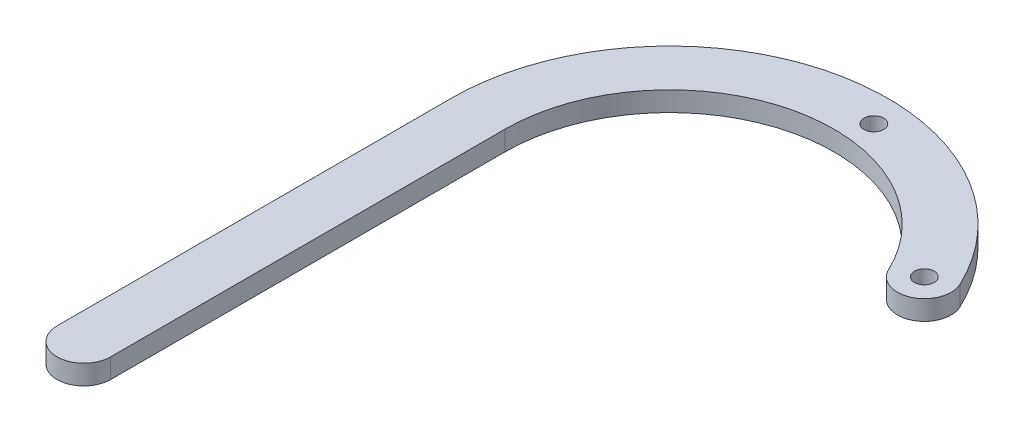
from build123d import *

# Parameters (mm, degrees)
BOSS_EXTRUDE1_DEPTH = 3.175
SKETCH5_R           = 1.5875
CUT_EXTRUDE1_DEPTH  = 4.175


with BuildPart() as part:
    # Sketch2 → Boss-Extrude1 (new body)
    with BuildSketch(Plane(origin=(0, 0, 0), x_dir=(1, 0, 0), z_dir=(0, 1, 0))):
        with BuildLine():
            Line((-64.433559451, -10.720044429), (-64.433559451, -74.220044429))
            ThreePointArc((-64.433559451, -74.220044429), (-60.115559451, -78.538044429), (-55.797559451, -74.220044429))
            Line((-55.797559451, -74.220044429), (-55.797559451, -10.720044429))
            ThreePointArc((-55.797559451, -10.720044429), (-35.103902349, 15.133874618), (-5.345262109, 0.605423034))
            ThreePointArc((-5.345262109, 0.605423034), (0.404037892, -1.452682281), (2.462143207, 4.296617721))
            ThreePointArc((2.462143207, 4.296617721), (-36.995428675, 23.560180104), (-64.433559451, -10.720044429))
        make_face()
    extrude(amount=BOSS_EXTRUDE1_DEPTH)

    # Sketch5 → Cut-Extrude1 (cut, through all)
    with BuildSketch(Plane(origin=(0, 3.175, 0), x_dir=(1, 0, 0), z_dir=(0, 1, 0))):
        with Locations((-26.841559451, 19.723020377)):
            Circle(SKETCH5_R)
        with Locations((-1.441559451, 2.451020377)):
            Circle(SKETCH5_R)
    extrude(amount=-CUT_EXTRUDE1_DEPTH, mode=Mode.SUBTRACT)


solid = part.part
